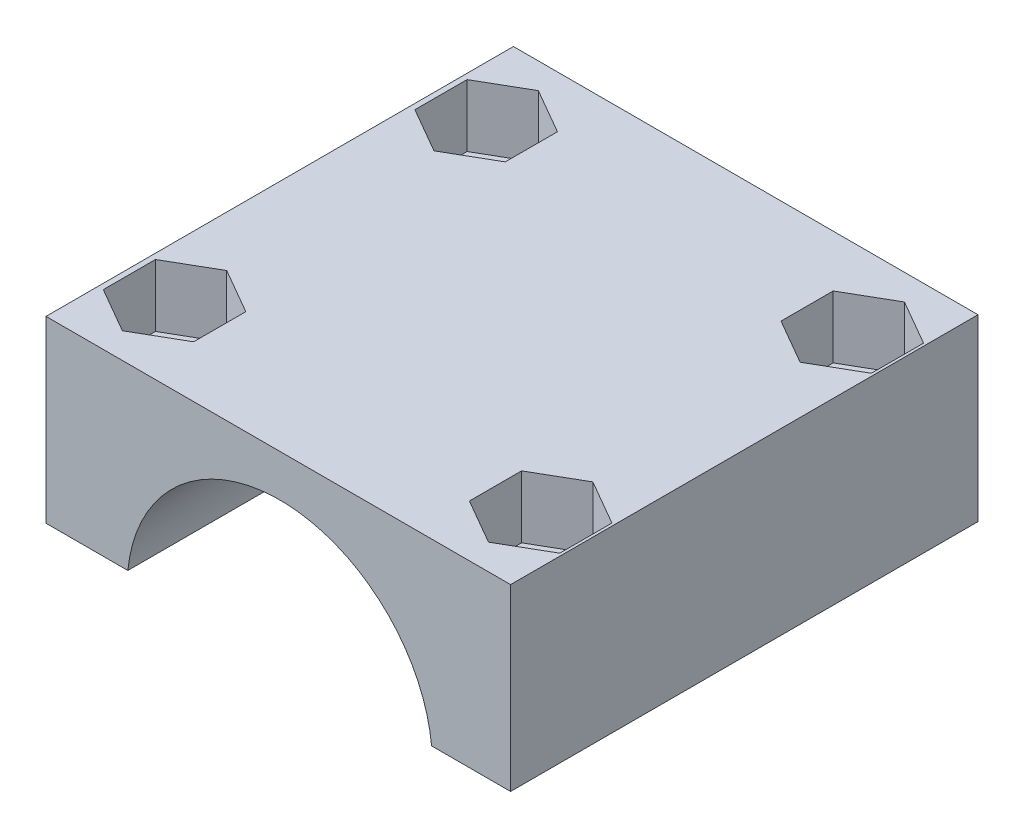
from build123d import *

# Parameters (mm, degrees)
AUFSATZ_LINEAR_AUSTRAGEN1_DEPTH = 30
F_3_0_3_DURCHMESSER_BOHRUNG1_D  = 3
SCHNITT_LINEAR_AUSTRAGEN1_DEPTH = 4


with BuildPart() as part:
    # Skizze1 → Aufsatz-Linear austragen1 (new body)
    with BuildSketch(Plane.XY):
        with BuildLine():
            Line((-63.596153483, 25.865230167), (-58.344999569, 25.865230167))
            ThreePointArc((-58.344999569, 25.865230167), (-48.596153483, 34.665230167), (-38.847307398, 25.865230167))
            Line((-38.847307398, 25.865230167), (-34.847307398, 25.865230167))
            Line((-34.847307398, 25.865230167), (-34.176711032, 25.865230167))
            Line((-34.176711032, 25.865230167), (-33.778455993, 25.865230167))
            Line((-33.778455993, 25.865230167), (-33.778455993, 37.365230166))
            Line((-33.778455993, 37.365230166), (-34.847307398, 37.365230166))
            Line((-34.847307398, 37.365230166), (-48.596153483, 37.365230166))
            Line((-48.596153483, 37.365230166), (-63.596153483, 37.365230166))
            Line((-63.596153483, 37.365230166), (-63.596153483, 25.865230167))
        make_face()
    extrude(amount=-AUFSATZ_LINEAR_AUSTRAGEN1_DEPTH)

    # Ø3.0 (3) Durchmesser Bohrung1 (through all)
    with Locations(Plane(origin=(0, 37.365230166, 0), x_dir=(1, 0, 0), z_dir=(0, 1, 0))):
        with Locations((-36.847307398, 5), (-60.344999569, 5), (-60.344999569, 25), (-36.847307398, 25)):
            Hole(F_3_0_3_DURCHMESSER_BOHRUNG1_D / 2)

    # Skizze4 → Schnitt-Linear austragen1 (cut)
    with BuildSketch(Plane(origin=(0, 37.365230166, 0), x_dir=(1, 0, 0), z_dir=(0, 1, 0))):
        Polygon((-39.747307398, 26.674315781), (-39.747307398, 23.325684219), (-36.847307398, 21.651368439), (-33.947307398, 23.325684219), (-33.947307398, 26.674315781), (-36.847307398, 28.348631561), align=None)
        Polygon((-60.344999569, 28.348631561), (-63.244999569, 26.674315781), (-63.244999569, 23.325684219), (-60.344999569, 21.651368439), (-57.444999569, 23.325684219), (-57.444999569, 26.674315781), align=None)
        Polygon((-63.244999569, 6.674315781), (-63.244999569, 3.325684219), (-60.344999569, 1.651368439), (-57.444999569, 3.325684219), (-57.444999569, 6.674315781), (-60.344999569, 8.348631561), align=None)
        Polygon((-36.847307398, 8.348631561), (-39.747307398, 6.674315781), (-39.747307398, 3.325684219), (-36.847307398, 1.651368439), (-33.947307398, 3.325684219), (-33.947307398, 6.674315781), align=None)
    extrude(amount=-SCHNITT_LINEAR_AUSTRAGEN1_DEPTH, mode=Mode.SUBTRACT)


solid = part.part
